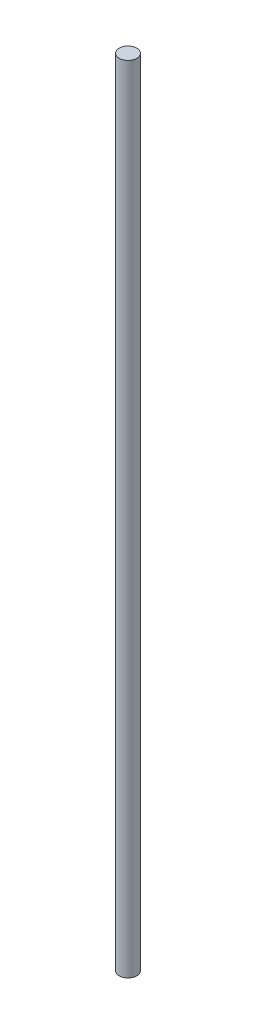
from build123d import *

# Parameters (mm, degrees)
CROQUIS1_R              = 4
SALIENTE_EXTRUIR1_DEPTH = 360


with BuildPart() as part:
    # Croquis1 → Saliente-Extruir1 (new body)
    with BuildSketch(Plane(origin=(0, 0, 0), x_dir=(1, 0, 0), z_dir=(0, 1, 0))):
        Circle(CROQUIS1_R)
    extrude(amount=SALIENTE_EXTRUIR1_DEPTH)


solid = part.part
